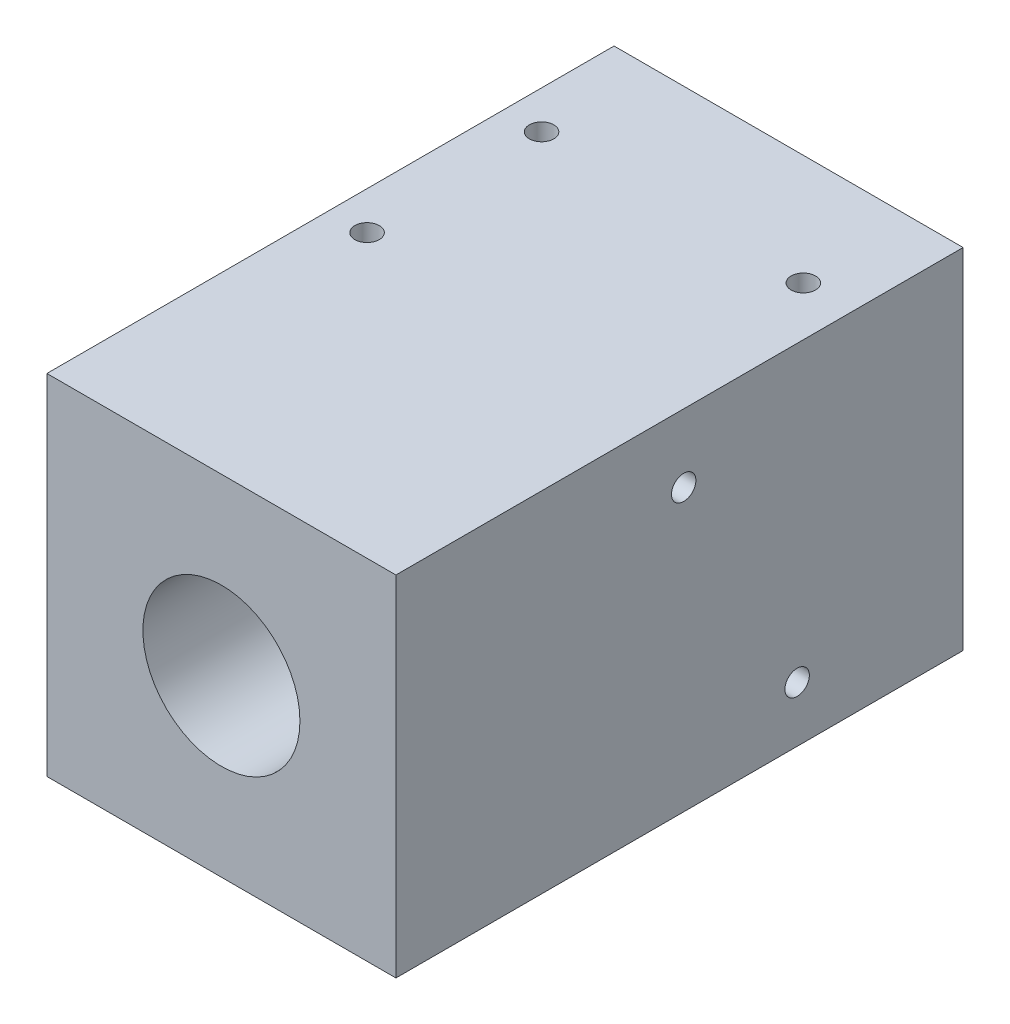
from build123d import *

# Parameters (mm, degrees)
SKETCH1_W           = 40
SKETCH1_H           = 40
SKETCH1_R           = 9
BOSS_EXTRUDE1_DEPTH = 65
SKETCH2_R           = 1.4
CUT_EXTRUDE1_DEPTH  = 41
SKETCH3_R           = 1.4
CUT_EXTRUDE2_DEPTH  = 65


with BuildPart() as part:
    # Sketch1 → Boss-Extrude1 (new body)
    with BuildSketch(Plane.XY):
        Rectangle(SKETCH1_W, SKETCH1_H)
        Circle(SKETCH1_R, mode=Mode.SUBTRACT)
    extrude(amount=BOSS_EXTRUDE1_DEPTH)

    # Sketch2 → Cut-Extrude1 (cut, through all)
    with BuildSketch(Plane(origin=(0, 20, 0), x_dir=(1, 0, 0), z_dir=(0, 1, 0))):
        with Locations((14.364756044, -12.672944901)):
            Circle(SKETCH2_R)
        with Locations((-15.635243956, -32.672944901)):
            Circle(SKETCH2_R)
        with Locations((-15.635243956, -12.672944901)):
            Circle(SKETCH2_R)
    extrude(amount=-CUT_EXTRUDE1_DEPTH, mode=Mode.SUBTRACT)

    # Sketch3 → Cut-Extrude2 (cut)
    with BuildSketch(Plane(origin=(20, 0, 0), x_dir=(0, 0, -1), z_dir=(1, 0, 0))):
        with Locations((-32.021199164, 12.205306236)):
            Circle(SKETCH3_R)
        with Locations((-19.021201071, -13.641280886)):
            Circle(SKETCH3_R)
    extrude(amount=-CUT_EXTRUDE2_DEPTH, mode=Mode.SUBTRACT)


solid = part.part
